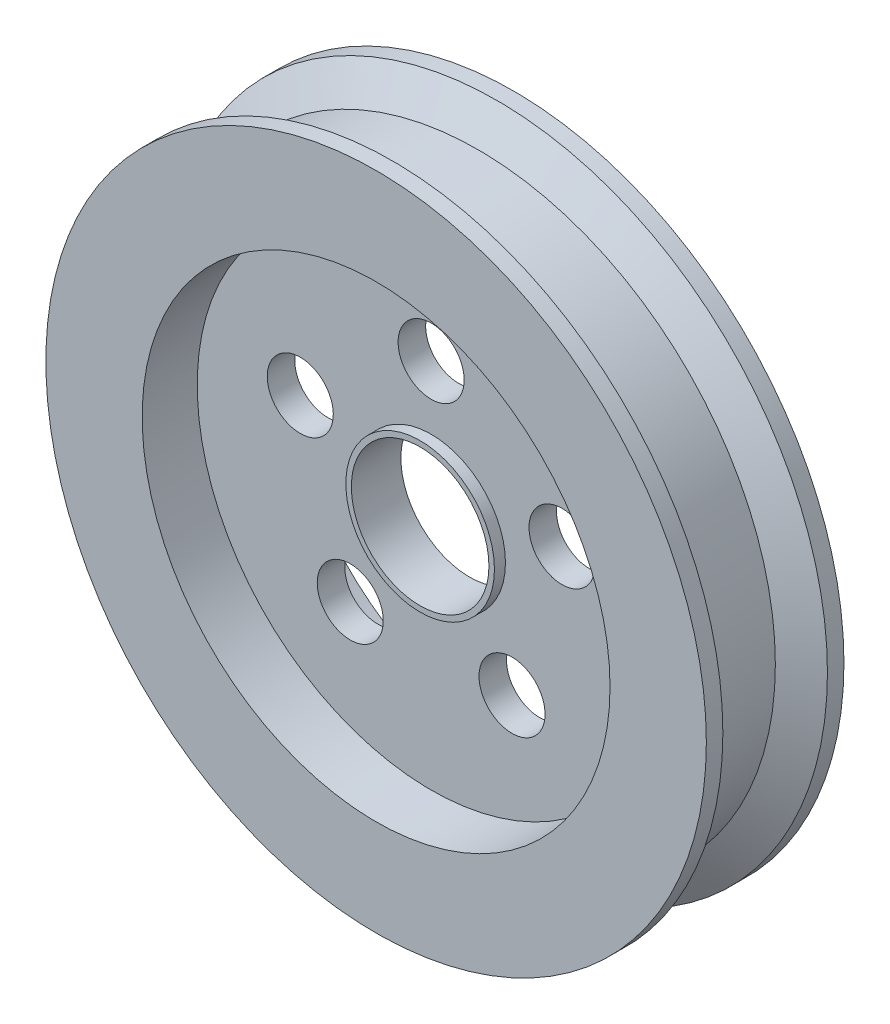
from build123d import *

# Parameters (mm, degrees)
SKETCH1_R                = 60
SKETCH1_R_2              = 12.5
BOSS_EXTRUDE1_DEPTH      = 12.5
SKETCH2_R                = 42.5
CUT_EXTRUDE1_DEPTH       = 10
SKETCH3_R                = 6
CUT_EXTRUDE2_DEPTH       = 10
CIRPATTERN1_COUNT        = 5
SKETCH5_R                = 13.5
SKETCH5_R_2              = 12.5
BOSS_EXTRUDE2_DEPTH      = 2
BOSS_EXTRUDE2_DEPTH_BACK = 7


with BuildPart() as part:
    # Sketch1 → Boss-Extrude1 (new body, symmetric)
    with BuildSketch(Plane.XY):
        Circle(SKETCH1_R)
        Circle(SKETCH1_R_2, mode=Mode.SUBTRACT)
    extrude(amount=BOSS_EXTRUDE1_DEPTH, both=True)

    # Sketch2 → Cut-Extrude1 (cut)
    with BuildSketch(Plane.XY.offset(12.5)):
        Circle(SKETCH2_R)
    cut_extrude1 = extrude(amount=-CUT_EXTRUDE1_DEPTH, mode=Mode.SUBTRACT)

    # Mirror1: Cut-Extrude1 across plane
    add(cut_extrude1.mirror(Plane.XY), mode=Mode.SUBTRACT)

    # Sketch3 → Cut-Extrude2 (cut)
    with BuildSketch(Plane.XY.offset(2.5)):
        with Locations((0, 25)):
            Circle(SKETCH3_R)
    cut_extrude2 = extrude(amount=-CUT_EXTRUDE2_DEPTH, mode=Mode.SUBTRACT)

    # CirPattern1: Cut-Extrude2 ×5 about axis
    cirpattern1_axis = Axis((0, 0, 0), (0, 0, 1))
    for i in range(1, CIRPATTERN1_COUNT):
        add(cut_extrude2.rotate(cirpattern1_axis, i * 360 / CIRPATTERN1_COUNT), mode=Mode.SUBTRACT)

    # Sketch4 → Cut-Revolve1 (revolve, cut)
    with BuildSketch(Plane(origin=(0, 0, 0), x_dir=(1, 0, 0), z_dir=(0, 1, 0))):
        Polygon((60, 9.5), (60, -9.5), (54, -6.035898385), (54, 6.035898385), align=None)
    revolve(axis=Axis((0, 0, 0), (0, 0, -1)), mode=Mode.SUBTRACT)

    # Sketch5 → Boss-Extrude2 (add, two sides)
    with BuildSketch(Plane.XY.offset(2.5)) as boss_extrude2_sk:
        Circle(SKETCH5_R)
        Circle(SKETCH5_R_2, mode=Mode.SUBTRACT)
    extrude(amount=BOSS_EXTRUDE2_DEPTH)
    extrude(boss_extrude2_sk.sketch, amount=-BOSS_EXTRUDE2_DEPTH_BACK)


solid = part.part
